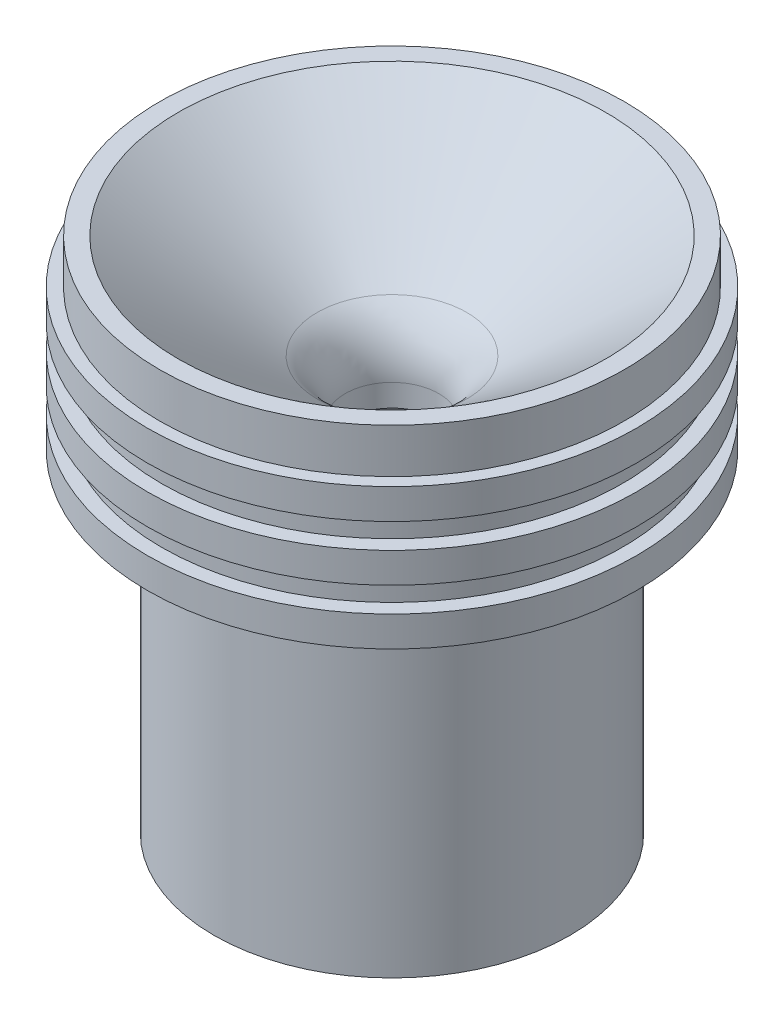
from build123d import *


with BuildPart() as part:
    # Sketch1 → Revolve1 (revolve)
    with BuildSketch(Plane.XY):
        with BuildLine():
            Line((-6.6802, 0), (-6.6802, -3.175))
            Line((-6.6802, -3.175), (-21.279532816, -50.92726597))
            Line((-21.279532816, -50.92726597), (-25.3996444, -50.92726597))
            Line((-25.3996444, -50.92726597), (-25.3996444, -3.55626597))
            Line((-25.3996444, -3.55626597), (-34.8992444, -3.55626597))
            Line((-34.8992444, -3.55626597), (-34.8992444, 0.76173403))
            Line((-34.8992444, 0.76173403), (-32.8672444, 0.76173403))
            Line((-32.8672444, 0.76173403), (-32.8672444, 4.31773403))
            Line((-32.8672444, 4.31773403), (-34.8992444, 4.31773403))
            Line((-34.8992444, 4.31773403), (-34.8992444, 8.63573403))
            Line((-34.8992444, 8.63573403), (-32.8672444, 8.63573403))
            Line((-32.8672444, 8.63573403), (-32.8672444, 12.19173403))
            Line((-32.8672444, 12.19173403), (-34.8992444, 12.19173403))
            Line((-34.8992444, 12.19173403), (-34.8992444, 16.50973403))
            Line((-34.8992444, 16.50973403), (-33.1466444, 16.50973403))
            Line((-33.1466444, 16.50973403), (-33.1466444, 22.85973403))
            Line((-33.1466444, 22.85973403), (-30.49397, 22.85973403))
            Line((-30.49397, 22.85973403), (-10.691104238, 8.018327423))
            ThreePointArc((-10.691104238, 8.018327423), (-7.73884947, 4.482770557), (-6.6802, 0))
        make_face()
    revolve(axis=Axis((0, 0, 0), (0, -1, 0)))


solid = part.part
